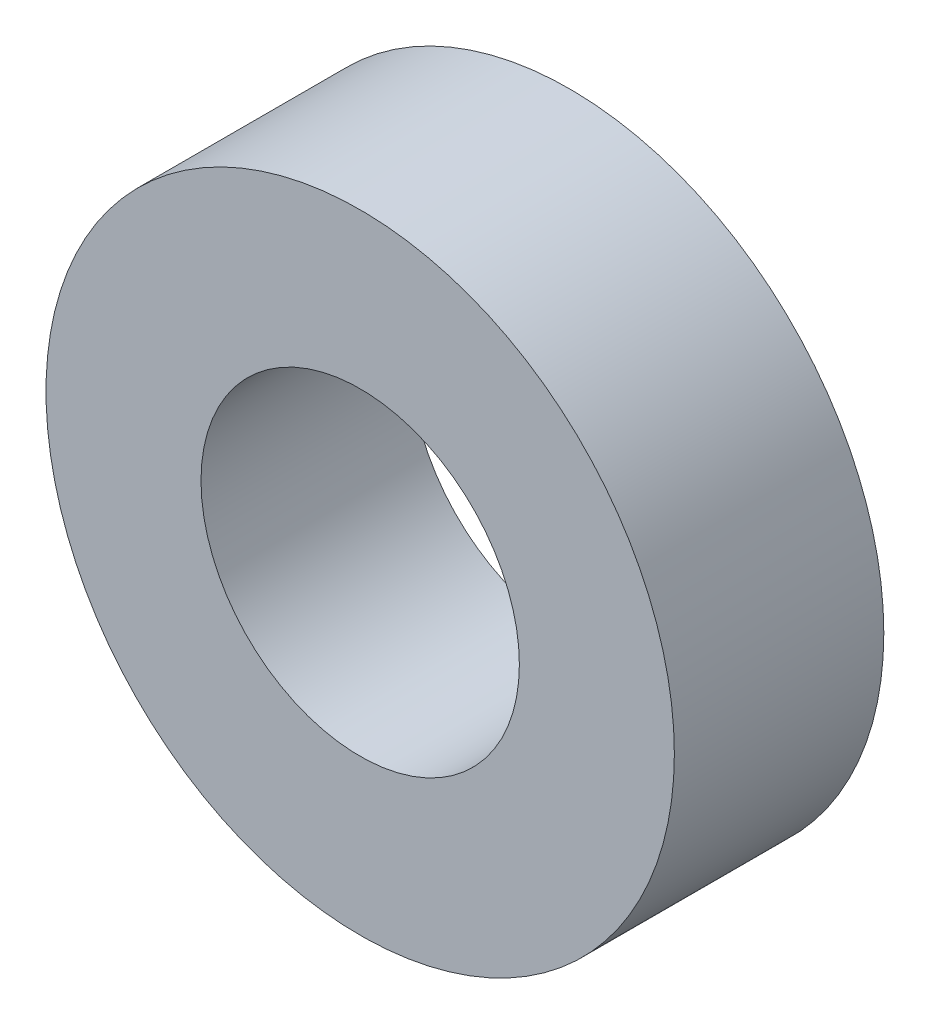
from build123d import *

# Parameters (mm, degrees)
SKETCH1_R      = 9.525
SKETCH1_R_2    = 4.826
EXTRUDE1_DEPTH = 3.175


with BuildPart() as part:
    # Sketch1 → Extrude1 (new body, symmetric)
    with BuildSketch(Plane.XY):
        Circle(SKETCH1_R)
        Circle(SKETCH1_R_2, mode=Mode.SUBTRACT)
    extrude(amount=EXTRUDE1_DEPTH, both=True)


solid = part.part
